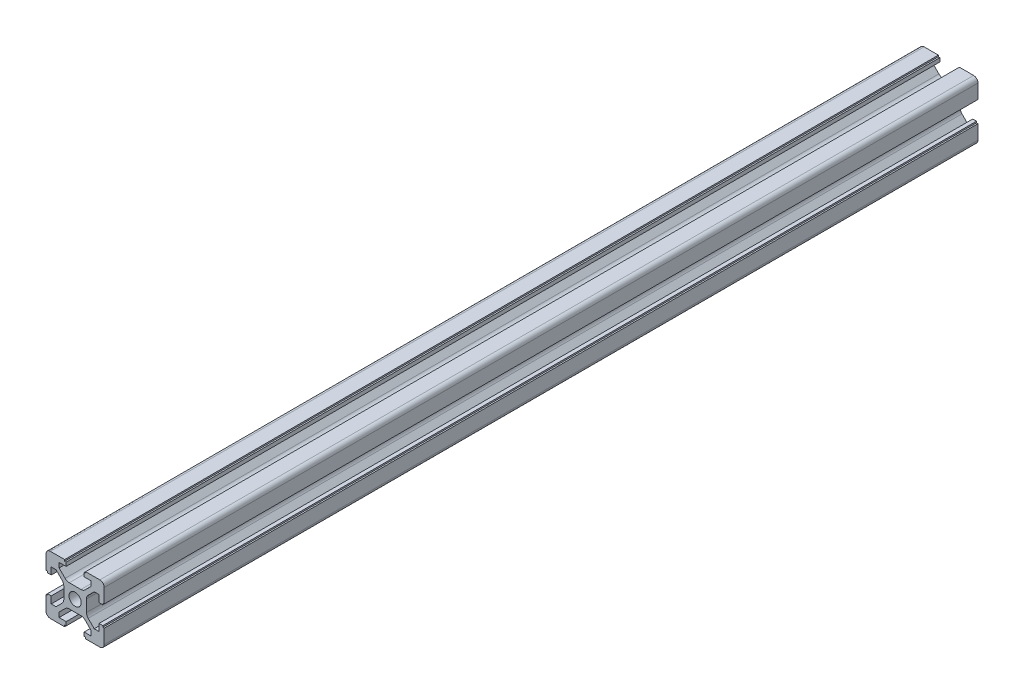
from build123d import *

# Parameters (mm, degrees)
SKETCH_1_R      = 2.1
EXTRUDE_1_DEPTH = 150


with BuildPart() as part:
    # 草图1 → 凸台-拉伸1 (new body, symmetric)
    with BuildSketch(Plane.XY):
        with BuildLine():
            Line((-3.425126266, 4.485786438), (-5.5, 6.560660172))
            Line((-5.5, 6.560660172), (-5.5, 8.2))
            Line((-5.5, 8.2), (-3.1, 8.2))
            Line((-3.1, 8.2), (-3.1, 9.5))
            Line((-3.1, 9.5), (-3.6, 9.5))
            Line((-3.6, 9.5), (-3.6, 10))
            Line((-3.6, 10), (-8.5, 10))
            ThreePointArc((-8.5, 10), (-9.560660172, 9.560660172), (-10, 8.5))
            Line((-10, 8.5), (-10, 3.6))
            Line((-10, 3.6), (-9.5, 3.6))
            Line((-9.5, 3.6), (-9.5, 3.1))
            Line((-9.5, 3.1), (-8.2, 3.1))
            Line((-8.2, 3.1), (-8.2, 5.5))
            Line((-8.2, 5.5), (-6.560660172, 5.5))
            Line((-6.560660172, 5.5), (-4.485786438, 3.425126266))
            ThreePointArc((-4.485786438, 3.425126266), (-4.052240935, 2.776279568), (-3.9, 2.010912703))
            Line((-3.9, 2.010912703), (-3.9, -2.010912703))
            ThreePointArc((-3.9, -2.010912703), (-4.052240935, -2.776279568), (-4.485786438, -3.425126266))
            Line((-4.485786438, -3.425126266), (-6.560660172, -5.5))
            Line((-6.560660172, -5.5), (-8.2, -5.5))
            Line((-8.2, -5.5), (-8.2, -3.1))
            Line((-8.2, -3.1), (-9.5, -3.1))
            Line((-9.5, -3.1), (-9.5, -3.6))
            Line((-9.5, -3.6), (-10, -3.6))
            Line((-10, -3.6), (-10, -8.5))
            ThreePointArc((-10, -8.5), (-9.560660172, -9.560660172), (-8.5, -10))
            Line((-8.5, -10), (-3.6, -10))
            Line((-3.6, -10), (-3.6, -9.5))
            Line((-3.6, -9.5), (-3.1, -9.5))
            Line((-3.1, -9.5), (-3.1, -8.2))
            Line((-3.1, -8.2), (-5.5, -8.2))
            Line((-5.5, -8.2), (-5.5, -6.560660172))
            Line((-5.5, -6.560660172), (-3.425126266, -4.485786438))
            ThreePointArc((-3.425126266, -4.485786438), (-2.776279568, -4.052240935), (-2.010912703, -3.9))
            Line((-2.010912703, -3.9), (2.010912703, -3.9))
            ThreePointArc((2.010912703, -3.9), (2.776279568, -4.052240935), (3.425126266, -4.485786438))
            Line((3.425126266, -4.485786438), (5.5, -6.560660172))
            Line((5.5, -6.560660172), (5.5, -8.2))
            Line((5.5, -8.2), (3.1, -8.2))
            Line((3.1, -8.2), (3.1, -9.5))
            Line((3.1, -9.5), (3.6, -9.5))
            Line((3.6, -9.5), (3.6, -10))
            Line((3.6, -10), (8.5, -10))
            ThreePointArc((8.5, -10), (9.560660172, -9.560660172), (10, -8.5))
            Line((10, -8.5), (10, -3.6))
            Line((10, -3.6), (9.5, -3.6))
            Line((9.5, -3.6), (9.5, -3.1))
            Line((9.5, -3.1), (8.2, -3.1))
            Line((8.2, -3.1), (8.2, -5.5))
            Line((8.2, -5.5), (6.560660172, -5.5))
            Line((6.560660172, -5.5), (4.485786438, -3.425126266))
            ThreePointArc((4.485786438, -3.425126266), (4.052240935, -2.776279568), (3.9, -2.010912703))
            Line((3.9, -2.010912703), (3.9, 2.010912703))
            ThreePointArc((3.9, 2.010912703), (4.052240935, 2.776279568), (4.485786438, 3.425126266))
            Line((4.485786438, 3.425126266), (6.560660172, 5.5))
            Line((6.560660172, 5.5), (8.2, 5.5))
            Line((8.2, 5.5), (8.2, 3.1))
            Line((8.2, 3.1), (9.5, 3.1))
            Line((9.5, 3.1), (9.5, 3.6))
            Line((9.5, 3.6), (10, 3.6))
            Line((10, 3.6), (10, 8.5))
            ThreePointArc((10, 8.5), (9.560660172, 9.560660172), (8.5, 10))
            Line((8.5, 10), (3.6, 10))
            Line((3.6, 10), (3.6, 9.5))
            Line((3.6, 9.5), (3.1, 9.5))
            Line((3.1, 9.5), (3.1, 8.2))
            Line((3.1, 8.2), (5.5, 8.2))
            Line((5.5, 8.2), (5.5, 6.560660172))
            Line((5.5, 6.560660172), (3.425126266, 4.485786438))
            ThreePointArc((3.425126266, 4.485786438), (2.776279568, 4.052240935), (2.010912703, 3.9))
            Line((2.010912703, 3.9), (-2.010912703, 3.9))
            ThreePointArc((-2.010912703, 3.9), (-2.776279568, 4.052240935), (-3.425126266, 4.485786438))
        make_face()
        Circle(SKETCH_1_R, mode=Mode.SUBTRACT)
    extrude(amount=EXTRUDE_1_DEPTH, both=True)


solid = part.part
